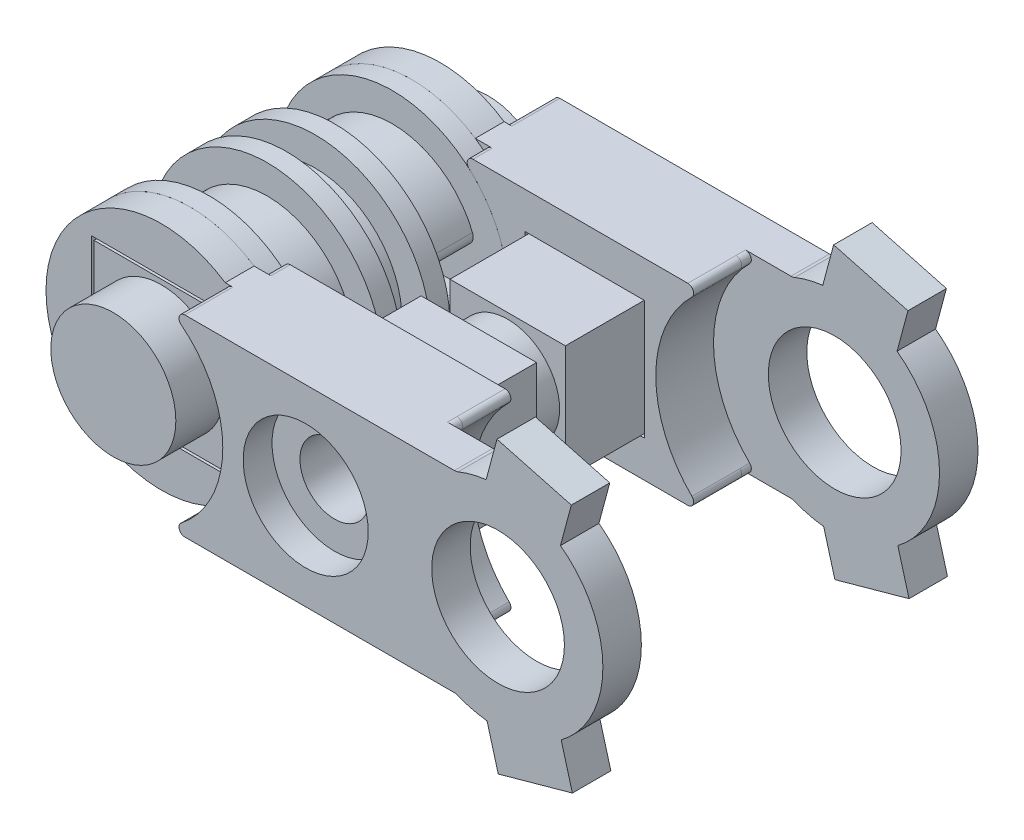
from build123d import *

# Parameters (mm, degrees)
SKETCH_1_R               = 4.5
EXTRUDE_1_DEPTH          = 3
SKETCH_2_R               = 6
EXTRUDE_2_DEPTH          = 1
EXTRUDE_START            = 1.5
SKETCH_3_R               = 4.5
EXTRUDE_3_DEPTH          = 1.5
SKETCH_4_R               = 6.000000000000001
EXTRUDE_4_DEPTH          = 1
EXTRUDE_START_2          = 3
SKETCH_5_R               = 4.5
EXTRUDE_5_DEPTH          = 3
SKETCH_6_R               = 6.000000000000001
EXTRUDE_6_DEPTH          = 1
EXTRUDE_START_3          = 1
SKETCH_7_R               = 6.000000000000001
EXTRUDE_7_DEPTH          = 1
EXTRUDE_10_DEPTH         = 1.5
SKETCH_11_R              = 3.25
EXTRUDE_11_DEPTH         = 2.5
EXTRUDE_12_DEPTH         = 1.5
EXTRUDE_13_DEPTH         = 0.5
FILLET_9_R               = 0.3
SKETCH_14_R              = 3.450000000000003
EXTRUDE_14_DEPTH         = 2
EXTRUDE_15_DEPTH         = 1
SKETCH_16_R              = 1.799999999999999
CUT_EXTRUDE_1_DEPTH      = 33.61828474950821
CUT_EXTRUDE_2_DEPTH      = 2
EXTRUDE_16_DEPTH         = 11.5
SKETCH_19_R              = 1.799999999999999
CUT_EXTRUDE_3_DEPTH      = 30.89903844607716
CUT_EXTRUDE_4_DEPTH      = 0.75
CUT_EXTRUDE_4_DEPTH_BACK = 0.75
SKETCH_20_R              = 2.6999999999999993
SKETCH_21_R              = 3.2500000000000027
CUT_EXTRUDE_5_DEPTH      = 1.5
CUT_EXTRUDE_6_DEPTH      = 1
EXTRUDE_17_DEPTH         = 2
EXTRUDE_18_DEPTH         = 2
SKETCH_25_W              = 3.0000000000000013
SKETCH_25_H              = 2
SKETCH_25_W_2            = 3
CUT_EXTRUDE_7_DEPTH      = 33.9517055037576
FILLET_10_R              = 0.5


with BuildPart() as part:
    # ｽｹｯﾁ1 → ﾎﾞｽ - 押し出し1 (new body)
    with BuildSketch(Plane.XY):
        Circle(SKETCH_1_R)
    extrude(amount=EXTRUDE_1_DEPTH)

    # ｽｹｯﾁ2 → ﾎﾞｽ - 押し出し2 (add)
    with BuildSketch(Plane(origin=(0, 0, 0), x_dir=(-1, 0, 0), z_dir=(0, 0, -1))):
        Circle(SKETCH_2_R)
    extrude(amount=EXTRUDE_2_DEPTH)

    # ｽｹｯﾁ3 → ﾎﾞｽ - 押し出し3 (add)
    with BuildSketch(Plane(origin=(0, 0, -1), x_dir=(-1, 0, 0), z_dir=(0, 0, -1)).offset(EXTRUDE_START)):
        with Locations(Location((0, 0, 0), (0, 0, 180))):
            Circle(SKETCH_3_R)
    extrude(amount=-EXTRUDE_3_DEPTH)

    # ｽｹｯﾁ4 → ﾎﾞｽ - 押し出し4 (add)
    with BuildSketch(Plane(origin=(0, 0, -2.5), x_dir=(-1, 0, 0), z_dir=(0, 0, -1))):
        Circle(SKETCH_4_R)
    extrude(amount=EXTRUDE_4_DEPTH)

    # ｽｹｯﾁ5 → ﾎﾞｽ - 押し出し5 (add)
    with BuildSketch(Plane(origin=(0, 0, -3.5), x_dir=(-1, 0, 0), z_dir=(0, 0, -1)).offset(EXTRUDE_START_2)):
        with Locations(Location((0, 0, 0), (0, 0, 180))):
            Circle(SKETCH_5_R)
    extrude(amount=-EXTRUDE_5_DEPTH)

    # ｽｹｯﾁ6 → ﾎﾞｽ - 押し出し6 (add)
    with BuildSketch(Plane(origin=(0, 0, -6.500000000000001), x_dir=(-1, 0, 0), z_dir=(0, 0, -1))):
        Circle(SKETCH_6_R)
    extrude(amount=EXTRUDE_6_DEPTH)

    # ｽｹｯﾁ7 → ﾎﾞｽ - 押し出し7 (add)
    with BuildSketch(Plane.XY.offset(3).offset(EXTRUDE_START_3)):
        with Locations(Location((0, 0, 0), (0, 0, 180))):
            Circle(SKETCH_7_R)
    extrude(amount=-EXTRUDE_7_DEPTH)

    # ｽｹｯﾁ10 → ﾎﾞｽ - 押し出し10 (add)
    with BuildSketch(Plane.XY.offset(4)):
        Polygon((3.4999999999999996, -3.5), (-3.5000000000000004, -3.500000000000001), (-3.5000000000000004, 3.5000000000000004), (3.4999999999999996, 3.5), align=None)
    extrude_10 = extrude(amount=EXTRUDE_10_DEPTH)

    # ｽｹｯﾁ11 → ﾎﾞｽ - 押し出し11 (add)
    with BuildSketch(Plane.XY.offset(5.5)):
        Circle(SKETCH_11_R)
    extrude_11 = extrude(amount=EXTRUDE_11_DEPTH)

    # ﾐﾗｰ1: ﾎﾞｽ - 押し出し10, ﾎﾞｽ - 押し出し11 across plane
    add(extrude_10.mirror(Plane.XY.offset(-1.7500000000000002)))
    add(extrude_11.mirror(Plane.XY.offset(-1.7500000000000002)))

    # ｽｹｯﾁ25 → ｶｯﾄ - 押し出し7 (cut, through all)
    with BuildSketch(Plane.ZY.offset(4.5)):
        with Locations((-5.000000000000001, 0)):
            Rectangle(SKETCH_25_W, SKETCH_25_H)
        with Locations((1.5, 0)):
            Rectangle(SKETCH_25_W_2, SKETCH_25_H)
    extrude(amount=-CUT_EXTRUDE_7_DEPTH, mode=Mode.SUBTRACT)

    # ﾌｨﾚｯﾄ10
    fillet_10_edges = [part.edges().sort_by_distance(p)[0] for p in [
        (4.387482193696061, 1, 1.5),
        (-4.387482193696061, 1, 1.5),
        (-4.387482193696061, -1, 1.5),
        (4.387482193696061, -1, 1.5),
        (-4.387482193696061, 1, -5),
        (4.387482193696061, 1, -5),
        (4.387482193696061, -1, -5),
        (-4.387482193696061, -1, -5),
    ]]
    fillet(fillet_10_edges, radius=FILLET_10_R)


with BuildPart() as body_2:
    # ｽｹｯﾁ12 → ﾎﾞｽ - 押し出し12 (new body)
    with BuildSketch(Plane.XY.offset(4)):
        with BuildLine():
            Line((3.3166247903554016, 5), (16.167246420652642, 5))
            ThreePointArc((16.167246420652642, 5), (13.700000000000001, 3.57e-15), (16.16724642065264, -5))
            Line((16.16724642065264, -5), (3.3166247903553985, -5.000000000000003))
            ThreePointArc((3.3166247903553985, -5.000000000000003), (-6.000000000000001, 7.3e-16), (3.3166247903554016, 5))
        make_face()
        Polygon((3.6399999999999997, -3.64), (3.6399999999999997, 3.64), (-3.6400000000000006, 3.6400000000000006), (-3.6400000000000006, -3.640000000000001), align=None, mode=Mode.SUBTRACT)
    extrude(amount=EXTRUDE_12_DEPTH)

    # ｽｹｯﾁ13 → ﾎﾞｽ - 押し出し13 (add)
    with BuildSketch(Plane.XY.offset(5.5)):
        with BuildLine():
            Line((15.366426864718767, 5.000000000000001), (3.71350238992787, 4.999999999999999))
            ThreePointArc((3.71350238992787, 4.999999999999999), (3.4301142319534543, 4.798443648448575), (3.5275172952737197, 4.464607679465777))
            ThreePointArc((3.5275172952737197, 4.464607679465777), (5.69, 3.16e-15), (3.527517295273725, -4.464607679465773))
            ThreePointArc((3.527517295273725, -4.464607679465773), (3.4301142319534588, -4.798443648448569), (3.713502389927875, -4.9999999999999964))
            Line((3.713502389927875, -4.9999999999999964), (15.366426864718758, -4.999999999999996))
            ThreePointArc((15.366426864718758, -4.999999999999996), (15.643997494550977, -4.813818036595895), (15.57704382541336, -4.486363636363631))
            ThreePointArc((15.57704382541336, -4.486363636363631), (13.7, 6.37e-15), (15.577043825413366, 4.486363636363639))
            ThreePointArc((15.577043825413366, 4.486363636363639), (15.643997494550984, 4.813818036595901), (15.366426864718767, 5.000000000000001))
        make_face()
    extrude(amount=EXTRUDE_13_DEPTH)

    # ﾌｨﾚｯﾄ9
    fillet_9_edges = [body_2.edges().sort_by_distance(p)[0] for p in [
        (16.16724642065264, -5.000000000000001, 4.75),
        (16.167246420652642, 5, 4.75),
    ]]
    fillet(fillet_9_edges, radius=FILLET_9_R)

    # ｽｹｯﾁ14 → ﾎﾞｽ - 押し出し14 (add)
    with BuildSketch(Plane.XY.offset(6)):
        with BuildLine():
            Line((3.71350238992787, 5), (17.73008810743677, 5))
            ThreePointArc((17.73008810743677, 5), (17.827318665969592, 5.00954488636839), (17.920837005971492, 5.03781512605042))
            ThreePointArc((17.920837005971492, 5.03781512605042), (25.45, 2.42e-15), (17.920837005971496, -5.037815126050422))
            ThreePointArc((17.920837005971496, -5.037815126050422), (17.827318665969596, -5.009544886368393), (17.730088107436774, -5.000000000000003))
            Line((17.730088107436774, -5.000000000000003), (3.713502389927875, -5.000000000000003))
            ThreePointArc((3.713502389927875, -5.000000000000003), (3.430114231953458, -4.79844364844857), (3.5275172952737246, -4.4646076794657725))
            ThreePointArc((3.5275172952737246, -4.4646076794657725), (5.69, 3.16e-15), (3.52751729527372, 4.464607679465777))
            ThreePointArc((3.52751729527372, 4.464607679465777), (3.4301142319534534, 4.798443648448575), (3.71350238992787, 5))
        make_face()
        with Locations((20, 0)):
            Circle(SKETCH_14_R, mode=Mode.SUBTRACT)
    extrude(amount=EXTRUDE_14_DEPTH)

    # ｽｹｯﾁ15 → ﾎﾞｽ - 押し出し15 (add)
    with BuildSketch(Plane(origin=(0, 0, 4), x_dir=(-1, 0, 0), z_dir=(0, 0, -1))):
        with BuildLine():
            Line((-15.366426864718765, 5), (-4.195235392680607, 5.000000000000001))
            ThreePointArc((-4.195235392680607, 5.000000000000001), (-3.9149294373899135, 4.806904496764971), (-3.9954622787434353, 4.476190476190477))
            ThreePointArc((-3.9954622787434353, 4.476190476190477), (-6.000000000000001, 7.3e-16), (-3.9954622787434353, -4.476190476190477))
            ThreePointArc((-3.9954622787434353, -4.476190476190477), (-3.9149294373899135, -4.806904496764971), (-4.195235392680607, -5.000000000000001))
            Line((-4.195235392680607, -5.000000000000001), (-15.366426864718763, -5))
            ThreePointArc((-15.366426864718763, -5), (-15.643997494550984, -4.813818036595896), (-15.577043825413359, -4.48636363636363))
            ThreePointArc((-15.577043825413359, -4.48636363636363), (-13.700000000000001, 4.2e-15), (-15.577043825413364, 4.486363636363636))
            ThreePointArc((-15.577043825413364, 4.486363636363636), (-15.643997494550984, 4.813818036595898), (-15.366426864718765, 5))
        make_face()
    extrude(amount=EXTRUDE_15_DEPTH)


with BuildPart() as body_3:
    # ﾐﾗｰ2: mirrored copy
    add(body_2.part.mirror(Plane.XY.offset(-1.7500000000000002)))


with BuildPart() as cut_extrude_1_tool:
    # ｽｹｯﾁ16 → ｶｯﾄ - 押し出し1 (new, through all)
    with BuildSketch(Plane.XY.offset(8)):
        with Locations((10, 0)):
            Circle(SKETCH_16_R)
    extrude(amount=-CUT_EXTRUDE_1_DEPTH)


with BuildPart() as body_2_1:
    add(body_2.part)

    # ｶｯﾄ - 押し出し1: cut by cut_extrude_1_tool
    add(cut_extrude_1_tool.part, mode=Mode.SUBTRACT)

    # ｽｹｯﾁ18 → ﾎﾞｽ - 押し出し16 (add)
    with BuildSketch(Plane(origin=(0, 0, 3), x_dir=(-1, 0, 0), z_dir=(0, 0, -1))):
        Polygon((-7.000000000000002, 2.9999999999999996), (-13.000000000000002, 2.9999999999999987), (-13.000000000000002, -2.9999999999999996), (-7.000000000000002, -2.999999999999999), align=None)
    extrude(amount=EXTRUDE_16_DEPTH)

    # ｽｹｯﾁ19 → ｶｯﾄ - 押し出し3 (cut, through all)
    with BuildSketch(Plane.XY.offset(3)):
        with Locations((10, 0)):
            Circle(SKETCH_19_R)
    extrude(amount=-CUT_EXTRUDE_3_DEPTH, mode=Mode.SUBTRACT)

    # ｽｹｯﾁ20 → ｶｯﾄ - 押し出し4 (cut, two sides: drawn at the far end of the back side and taken through both)
    with BuildSketch(Plane.XY.offset(-1.7500000000000002).offset(-CUT_EXTRUDE_4_DEPTH_BACK)):
        Polygon((13.000000000000002, 2.9999999999999987), (7.000000000000002, 2.9999999999999996), (7.000000000000002, -2.999999999999999), (13.000000000000002, -2.9999999999999996), align=None)
        with Locations((10, 0)):
            Circle(SKETCH_20_R, mode=Mode.SUBTRACT)
    extrude(amount=CUT_EXTRUDE_4_DEPTH + CUT_EXTRUDE_4_DEPTH_BACK, mode=Mode.SUBTRACT)

    # ｽｹｯﾁ21 → ｶｯﾄ - 押し出し5 (cut)
    with BuildSketch(Plane.XY.offset(8)):
        with Locations((10, 0)):
            Circle(SKETCH_21_R)
    extrude(amount=-CUT_EXTRUDE_5_DEPTH, mode=Mode.SUBTRACT)

    # ｽｹｯﾁ23 → ﾎﾞｽ - 押し出し17 (add)
    with BuildSketch(Plane.XY.offset(8)):
        Polygon((19.012837862046062, 4.043267356160144), (22.87654116720234, 3.0079911757500586), (23.808289729571413, 6.485324150390705), (19.94458642441514, 7.520600330800791), align=None)
        Polygon((20.010217320150122, -7.52079753791903), (23.864739132984617, -6.451844033605999), (22.902680979102882, -2.9827744020549556), (19.04815916626839, -4.051727906367987), align=None)
    extrude(amount=-EXTRUDE_17_DEPTH)


with BuildPart() as body_3_1:
    add(body_3.part)

    # ｶｯﾄ - 押し出し1: cut by cut_extrude_1_tool
    add(cut_extrude_1_tool.part, mode=Mode.SUBTRACT)

    # ｽｹｯﾁ17 → ｶｯﾄ - 押し出し2 (cut)
    with BuildSketch(Plane.XY.offset(-6.500000000000001)):
        Polygon((13.100000000000001, -3.0999999999999996), (6.900000000000001, -3.1000000000000005), (6.900000000000001, 3.0999999999999996), (13.100000000000001, 3.1000000000000005), align=None)
    extrude(amount=-CUT_EXTRUDE_2_DEPTH, mode=Mode.SUBTRACT)

    # ｽｹｯﾁ22 → ｶｯﾄ - 押し出し6 (cut)
    with BuildSketch(Plane(origin=(0, 0, -11.5), x_dir=(-1, 0, 0), z_dir=(0, 0, -1))):
        Polygon((-11.674315780649914, 2.8999999999999995), (-13.348631561299829, 1e-17), (-11.674315780649913, -2.900000000000001), (-8.325684219350087, -2.9000000000000004), (-6.651368438700171, -8.7e-16), (-8.325684219350087, 2.9), align=None)
    extrude(amount=-CUT_EXTRUDE_6_DEPTH, mode=Mode.SUBTRACT)

    # ｽｹｯﾁ24 → ﾎﾞｽ - 押し出し18 (add)
    with BuildSketch(Plane(origin=(0, 0, -11.5), x_dir=(-1, 0, 0), z_dir=(0, 0, -1))):
        Polygon((-22.87654116720234, 3.0079911757500586), (-19.012837862046062, 4.043267356160144), (-19.94458642441514, 7.520600330800791), (-23.808289729571413, 6.485324150390705), align=None)
        Polygon((-23.864739132984617, -6.451844033605999), (-20.010217320150122, -7.52079753791903), (-19.04815916626839, -4.051727906367987), (-22.902680979102882, -2.9827744020549556), align=None)
    extrude(amount=-EXTRUDE_18_DEPTH)


solid = Compound([part.part, body_2_1.part, body_3_1.part])
